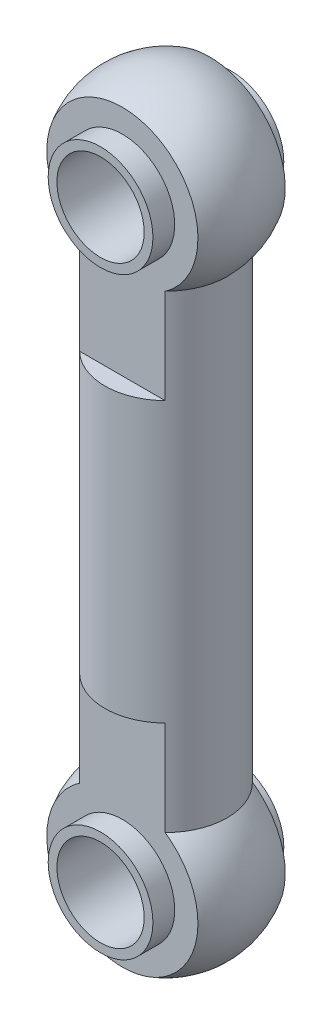
from build123d import *

# Parameters (mm, degrees)
SKETCH2_R               = 2.5
CUT_EXTRUDE1_DEPTH      = 6
CUT_EXTRUDE1_DEPTH_BACK = 6
SKETCH4_W               = 12
SKETCH4_H               = 18
CUT_EXTRUDE2_DEPTH      = 1.830127
SKETCH3_R               = 3
SKETCH3_R_2             = 2.5
EXTRUDE_THIN1_DEPTH     = 3.75


with BuildPart() as part:
    # Sketch1 → Revolve1 (revolve)
    with BuildSketch(Plane.XY):
        with BuildLine():
            Line((0, 0), (0, -7))
            Line((0, -7), (1.75, -7))
            Line((1.75, -7), (1.75, -17))
            Line((1.75, -17), (3.5, -17))
            Line((3.5, -17), (3.5, -3.570714214))
            ThreePointArc((3.5, -3.570714214), (4.628907596, 1.890294809), (0, 5))
            Line((0, 5), (0, 0))
        make_face()
    revolve(axis=Axis((0, 0, 0), (0, 1, 0)))

    # Sketch2 → Cut-Extrude1 (cut, two sides)
    with BuildSketch(Plane.XY) as cut_extrude1_sk:
        Circle(SKETCH2_R)
    extrude(amount=CUT_EXTRUDE1_DEPTH, mode=Mode.SUBTRACT)
    extrude(cut_extrude1_sk.sketch, amount=-CUT_EXTRUDE1_DEPTH_BACK, mode=Mode.SUBTRACT)

    # Sketch4 → Cut-Extrude2 (cut)
    with BuildSketch(Plane.XY.offset(2.5)):
        Rectangle(SKETCH4_W, SKETCH4_H)
    cut_extrude2 = extrude(amount=CUT_EXTRUDE2_DEPTH, mode=Mode.SUBTRACT)

    # Mirror1: Cut-Extrude2 across plane
    add(cut_extrude2.mirror(Plane.XY), mode=Mode.SUBTRACT)

    # Sketch3 → Extrude-Thin1 (add, symmetric)
    with BuildSketch(Plane.XY):
        Circle(SKETCH3_R)
        Circle(SKETCH3_R_2, mode=Mode.SUBTRACT)
    extrude(amount=EXTRUDE_THIN1_DEPTH, both=True)

    # Mirror2: part across plane


with BuildPart() as part_1:
    add(part.part)
    add(part.part.mirror(Plane(origin=(1.75, -17, 0), x_dir=(0, 0, 1), z_dir=(0, -1, 0))))


solid = part_1.part
